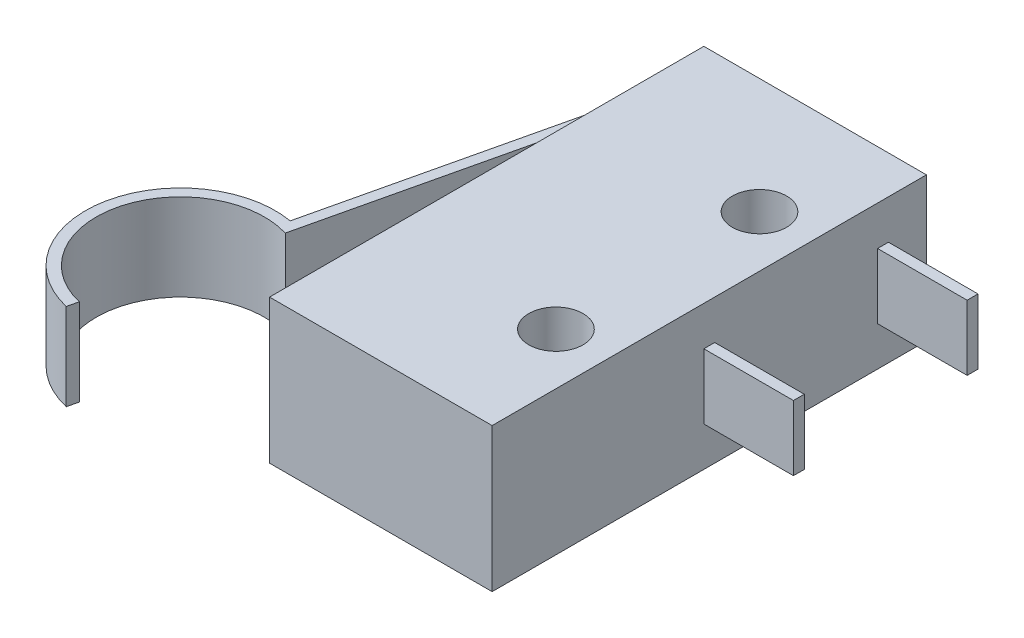
from build123d import *

# Parameters (mm, degrees)
SKETCH1_R           = 1.27
BOSS_EXTRUDE1_DEPTH = 3.3655
SKETCH1_3_W         = 4.191
SKETCH1_3_H         = 0.508
BOSS_EXTRUDE2_DEPTH = 1.524
BOSS_EXTRUDE3_DEPTH = 2.032


with BuildPart() as part:
    # Sketch1 → Boss-Extrude1 (new, symmetric)
    with BuildSketch(Plane(origin=(0, 0, 0), x_dir=(1, 0, 0), z_dir=(0, 1, 0))):
        Polygon((5.207, 8.382), (5.207, 10.16), (-5.207, 10.16), (-5.207, 7.493), (-5.207, 6.985), (-5.207, -10.16), (5.207, -10.16), (5.207, -0.254), (5.207, 0.254), (5.207, 7.874), align=None)
        with Locations((2.794, -4.7625)):
            Circle(SKETCH1_R, mode=Mode.SUBTRACT)
        with Locations((2.794, 4.7625)):
            Circle(SKETCH1_R, mode=Mode.SUBTRACT)
    extrude(amount=BOSS_EXTRUDE1_DEPTH, both=True)

    # Sketch1_3 → Boss-Extrude2 (add, symmetric)
    with BuildSketch(Plane(origin=(0, 0, 0), x_dir=(1, 0, 0), z_dir=(0, 1, 0))):
        with Locations((7.3025, 8.128)):
            Rectangle(SKETCH1_3_W, SKETCH1_3_H)
        with Locations((7.3025, 0)):
            Rectangle(SKETCH1_3_W, SKETCH1_3_H)
    extrude(amount=BOSS_EXTRUDE2_DEPTH, both=True)

    # Sketch1_4 → Boss-Extrude3 (add, symmetric)
    with BuildSketch(Plane(origin=(0, 0, 0), x_dir=(1, 0, 0), z_dir=(0, 1, 0))):
        with BuildLine():
            Line((-5.207, 6.985), (-5.207, 7.493))
            Line((-5.207, 7.493), (-6.170558218, 7.493))
            Line((-6.170558218, 7.493), (-9.145014336, -5.25524689))
            ThreePointArc((-9.145014336, -5.25524689), (-14.261834387, -8.748771053), (-10.915992225, -13.963356246))
            Line((-10.915992225, -13.963356246), (-10.800564542, -13.468643754))
            ThreePointArc((-10.800564542, -13.468643754), (-13.709152444, -8.616780848), (-8.76594289, -5.866301519))
            Line((-8.76594289, -5.866301519), (-5.767441782, 6.985))
            Line((-5.767441782, 6.985), (-5.207, 6.985))
        make_face()
    extrude(amount=BOSS_EXTRUDE3_DEPTH, both=True)


solid = part.part
